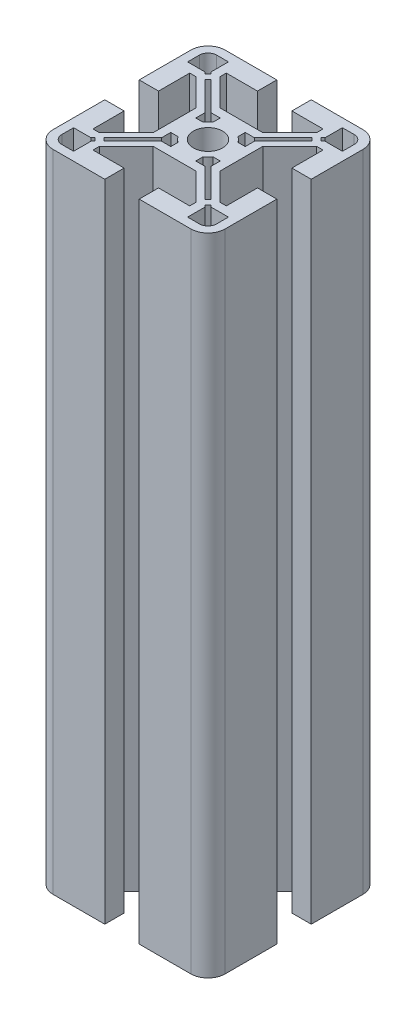
from build123d import *

# Parameters (mm, degrees)
BOSS_EXTRUDE1_DEPTH = 75


with BuildPart() as part:
    # Sketch1 → Boss-Extrude1 (new body, symmetric)
    with BuildSketch(Plane(origin=(0, 0, 0), x_dir=(1, 0, 0), z_dir=(0, 1, 0))):
        with BuildLine():
            Line((-27.932619, -6.859853), (-27.932619, 5.140147))
            ThreePointArc((-27.932619, 5.140147), (-26.761046, 7.968574), (-23.932619, 9.140147))
            Line((-23.932619, 9.140147), (-11.932619, 9.140147))
            Line((-11.932619, 9.140147), (-11.932619, 4.640147))
            Line((-11.932619, 4.640147), (-19.182619, 4.640147))
            Line((-19.182619, 4.640147), (-19.182619, 3.140147))
            Line((-19.182619, 3.140147), (-12.932619, -3.109853))
            Line((-12.932619, -3.109853), (-7.932619, -3.109853))
            Line((-7.932619, -3.109853), (-2.932619, -3.109853))
            Line((-2.932619, -3.109853), (3.317381, 3.140147))
            Line((3.317381, 3.140147), (3.317381, 4.640147))
            Line((3.317381, 4.640147), (-3.932619, 4.640147))
            Line((-3.932619, 4.640147), (-3.932619, 9.140147))
            Line((-3.932619, 9.140147), (8.067381, 9.140147))
            ThreePointArc((8.067381, 9.140147), (10.895808, 7.968574), (12.067381, 5.140147))
            Line((12.067381, 5.140147), (12.067381, -6.859853))
            Line((12.067381, -6.859853), (7.567381, -6.859853))
            Line((7.567381, -6.859853), (7.567381, 0.390147))
            Line((7.567381, 0.390147), (6.067381, 0.390147))
            Line((6.067381, 0.390147), (-0.182619, -5.859853))
            Line((-0.182619, -5.859853), (-0.182619, -10.859853))
            Line((-0.182619, -10.859853), (-0.182619, -15.859853))
            Line((-0.182619, -15.859853), (6.067381, -22.109853))
            Line((6.067381, -22.109853), (7.567381, -22.109853))
            Line((7.567381, -22.109853), (7.567381, -14.859853))
            Line((7.567381, -14.859853), (12.067381, -14.859853))
            Line((12.067381, -14.859853), (12.067381, -26.859853))
            ThreePointArc((12.067381, -26.859853), (10.895808, -29.68828), (8.067381, -30.859853))
            Line((8.067381, -30.859853), (-3.932619, -30.859853))
            Line((-3.932619, -30.859853), (-3.932619, -26.359853))
            Line((-3.932619, -26.359853), (3.317381, -26.359853))
            Line((3.317381, -26.359853), (3.317381, -24.859853))
            Line((3.317381, -24.859853), (-2.932619, -18.609853))
            Line((-2.932619, -18.609853), (-7.932619, -18.609853))
            Line((-7.932619, -18.609853), (-12.932619, -18.609853))
            Line((-12.932619, -18.609853), (-19.182619, -24.859853))
            Line((-19.182619, -24.859853), (-19.182619, -26.359853))
            Line((-19.182619, -26.359853), (-11.932619, -26.359853))
            Line((-11.932619, -26.359853), (-11.932619, -30.859853))
            Line((-11.932619, -30.859853), (-23.932619, -30.859853))
            ThreePointArc((-23.932619, -30.859853), (-26.761046, -29.68828), (-27.932619, -26.859853))
            Line((-27.932619, -26.859853), (-27.932619, -14.859853))
            Line((-27.932619, -14.859853), (-23.432619, -14.859853))
            Line((-23.432619, -14.859853), (-23.432619, -22.109853))
            Line((-23.432619, -22.109853), (-21.932619, -22.109853))
            Line((-21.932619, -22.109853), (-15.682619, -15.859853))
            Line((-15.682619, -15.859853), (-15.682619, -10.859853))
            Line((-15.682619, -10.859853), (-15.682619, -5.859853))
            Line((-15.682619, -5.859853), (-21.932619, 0.390147))
            Line((-21.932619, 0.390147), (-23.432619, 0.390147))
            Line((-23.432619, 0.390147), (-23.432619, -6.859853))
            Line((-23.432619, -6.859853), (-27.932619, -6.859853))
        make_face()
        with BuildLine():
            Line((-25.932619, 2.390147), (-25.932619, 5.140147))
            ThreePointArc((-25.932619, 5.140147), (-25.346832, 6.554361), (-23.932619, 7.140147))
            Line((-23.932619, 7.140147), (-21.182619, 7.140147))
            Line((-21.182619, 7.140147), (-21.182619, 3.097254))
            Line((-21.182619, 3.097254), (-20.734396, 2.649031))
            Line((-20.734396, 2.649031), (-21.441502, 1.941924))
            Line((-21.441502, 1.941924), (-21.889726, 2.390147))
            Line((-21.889726, 2.390147), (-25.932619, 2.390147))
        make_face(mode=Mode.SUBTRACT)
        with BuildLine():
            Line((-20.380842, 0.881264), (-13.682619, -5.816959))
            Line((-13.682619, -5.816959), (-13.682619, -7.955115))
            Line((-13.682619, -7.955115), (-13.182619, -7.955115))
            Line((-13.182619, -7.955115), (-12.002324, -7.955115))
            ThreePointArc((-12.002324, -7.955115), (-11.468153, -7.324319), (-10.837356, -6.790148))
            Line((-10.837356, -6.790148), (-10.837356, -5.609853))
            Line((-10.837356, -5.609853), (-10.837356, -5.109853))
            Line((-10.837356, -5.109853), (-12.975512, -5.109853))
            Line((-12.975512, -5.109853), (-19.673735, 1.588371))
            Line((-19.673735, 1.588371), (-20.380842, 0.881264))
        make_face(mode=Mode.SUBTRACT)
        with BuildLine():
            Line((10.067381, 2.390147), (10.067381, 5.140147))
            ThreePointArc((10.067381, 5.140147), (9.481595, 6.554361), (8.067381, 7.140147))
            Line((8.067381, 7.140147), (5.317381, 7.140147))
            Line((5.317381, 7.140147), (5.317381, 3.097254))
            Line((5.317381, 3.097254), (4.869158, 2.649031))
            Line((4.869158, 2.649031), (5.576265, 1.941924))
            Line((5.576265, 1.941924), (6.024488, 2.390147))
            Line((6.024488, 2.390147), (10.067381, 2.390147))
        make_face(mode=Mode.SUBTRACT)
        with BuildLine():
            Line((-2.182619, -5.816959), (-2.182619, -7.955115))
            Line((-2.182619, -7.955115), (-2.682619, -7.955115))
            Line((-2.682619, -7.955115), (-3.862914, -7.955115))
            ThreePointArc((-3.862914, -7.955115), (-4.397085, -7.324319), (-5.027881, -6.790148))
            Line((-5.027881, -6.790148), (-5.027881, -5.609853))
            Line((-5.027881, -5.609853), (-5.027881, -5.109853))
            Line((-5.027881, -5.109853), (-2.889726, -5.109853))
            Line((-2.889726, -5.109853), (3.808498, 1.588371))
            Line((3.808498, 1.588371), (4.515604, 0.881264))
            Line((4.515604, 0.881264), (-2.182619, -5.816959))
        make_face(mode=Mode.SUBTRACT)
        with BuildLine():
            Line((5.317381, -28.859853), (8.067381, -28.859853))
            ThreePointArc((8.067381, -28.859853), (9.481595, -28.274066), (10.067381, -26.859853))
            Line((10.067381, -26.859853), (10.067381, -24.109853))
            Line((10.067381, -24.109853), (6.024488, -24.109853))
            Line((6.024488, -24.109853), (5.576265, -23.661629))
            Line((5.576265, -23.661629), (4.869158, -24.368736))
            Line((4.869158, -24.368736), (5.317381, -24.816959))
            Line((5.317381, -24.816959), (5.317381, -28.859853))
        make_face(mode=Mode.SUBTRACT)
        with BuildLine():
            Line((-2.889726, -16.609853), (-5.027881, -16.609853))
            Line((-5.027881, -16.609853), (-5.027881, -16.109853))
            Line((-5.027881, -16.109853), (-5.027881, -14.929558))
            ThreePointArc((-5.027881, -14.929558), (-4.397085, -14.395387), (-3.862914, -13.76459))
            Line((-3.862914, -13.76459), (-2.682619, -13.76459))
            Line((-2.682619, -13.76459), (-2.182619, -13.76459))
            Line((-2.182619, -13.76459), (-2.182619, -15.902746))
            Line((-2.182619, -15.902746), (4.515604, -22.600969))
            Line((4.515604, -22.600969), (3.808498, -23.308076))
            Line((3.808498, -23.308076), (-2.889726, -16.609853))
        make_face(mode=Mode.SUBTRACT)
        with BuildLine():
            Line((-25.932619, -24.109853), (-25.932619, -26.859853))
            ThreePointArc((-25.932619, -26.859853), (-25.346832, -28.274066), (-23.932619, -28.859853))
            Line((-23.932619, -28.859853), (-21.182619, -28.859853))
            Line((-21.182619, -28.859853), (-21.182619, -24.816959))
            Line((-21.182619, -24.816959), (-20.734396, -24.368736))
            Line((-20.734396, -24.368736), (-21.441502, -23.661629))
            Line((-21.441502, -23.661629), (-21.889726, -24.109853))
            Line((-21.889726, -24.109853), (-25.932619, -24.109853))
        make_face(mode=Mode.SUBTRACT)
        with BuildLine():
            Line((-13.682619, -15.902746), (-13.682619, -13.76459))
            Line((-13.682619, -13.76459), (-13.182619, -13.76459))
            Line((-13.182619, -13.76459), (-12.002324, -13.76459))
            ThreePointArc((-12.002324, -13.76459), (-11.468153, -14.395387), (-10.837356, -14.929558))
            Line((-10.837356, -14.929558), (-10.837356, -16.109853))
            Line((-10.837356, -16.109853), (-10.837356, -16.609853))
            Line((-10.837356, -16.609853), (-12.975512, -16.609853))
            Line((-12.975512, -16.609853), (-19.673735, -23.308076))
            Line((-19.673735, -23.308076), (-20.380842, -22.600969))
            Line((-20.380842, -22.600969), (-13.682619, -15.902746))
        make_face(mode=Mode.SUBTRACT)
        with BuildLine():
            ThreePointArc((-11.332619, -10.859853), (-10.336782, -8.45569), (-7.932619, -7.459853))
            ThreePointArc((-7.932619, -7.459853), (-5.528456, -8.45569), (-4.532619, -10.859853))
            ThreePointArc((-4.532619, -10.859853), (-5.528456, -13.264016), (-7.932619, -14.259853))
            ThreePointArc((-7.932619, -14.259853), (-10.336782, -13.264016), (-11.332619, -10.859853))
        make_face(mode=Mode.SUBTRACT)
    extrude(amount=BOSS_EXTRUDE1_DEPTH, both=True)


solid = part.part
